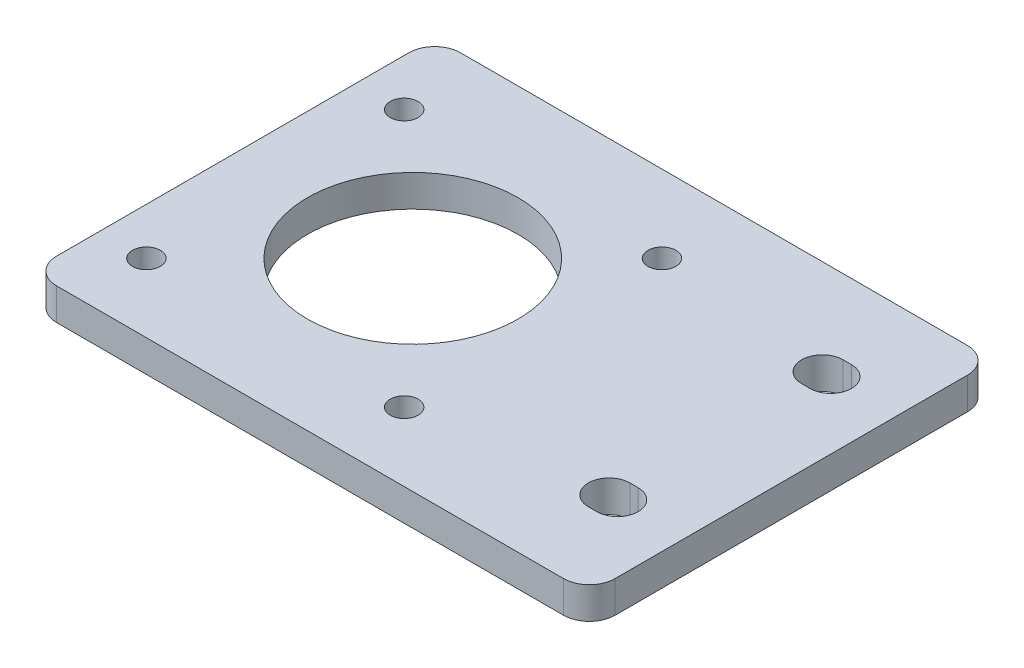
from build123d import *

# Parameters (mm, degrees)
SKETCH1_W           = 65
SKETCH1_H           = 47
SKETCH1_R           = 12.25
SKETCH1_R_2         = 1.623849847
BOSS_EXTRUDE1_DEPTH = 3.7
FILLET1_R           = 3


with BuildPart() as part:
    # Sketch1 → Boss-Extrude1 (new body)
    with BuildSketch(Plane(origin=(0, 0, 0), x_dir=(1, 0, 0), z_dir=(0, 1, 0))):
        with Locations((15.646990036, 10.777629745)):
            Rectangle(SKETCH1_W, SKETCH1_H)
        with Locations((4.096990036, 10.777629745)):
            Circle(SKETCH1_R, mode=Mode.SUBTRACT)
        with Locations((-11.403009964, -4.722370255)):
            Circle(SKETCH1_R_2, mode=Mode.SUBTRACT)
        with Locations((18.596990036, -4.722370255)):
            Circle(SKETCH1_R_2, mode=Mode.SUBTRACT)
        with Locations((18.596990036, 25.277629745)):
            Circle(SKETCH1_R_2, mode=Mode.SUBTRACT)
        with Locations((-11.403009964, 25.277629745)):
            Circle(SKETCH1_R_2, mode=Mode.SUBTRACT)
        with BuildLine():
            Line((39.356990036, 0.777629745), (40.336990036, 0.777629745))
            ThreePointArc((40.336990036, 0.777629745), (42.746990036, -1.632370255), (40.336990036, -4.042370255))
            Line((40.336990036, -4.042370255), (39.356990036, -4.042370255))
            ThreePointArc((39.356990036, -4.042370255), (36.946990036, -1.632370255), (39.356990036, 0.777629745))
        make_face(mode=Mode.SUBTRACT)
        with BuildLine():
            Line((39.356990036, 20.777629745), (40.336990036, 20.777629745))
            ThreePointArc((40.336990036, 20.777629745), (42.746990036, 23.187629745), (40.336990036, 25.597629745))
            Line((40.336990036, 25.597629745), (39.356990036, 25.597629745))
            ThreePointArc((39.356990036, 25.597629745), (36.946990036, 23.187629745), (39.356990036, 20.777629745))
        make_face(mode=Mode.SUBTRACT)
    extrude(amount=BOSS_EXTRUDE1_DEPTH)

    # Fillet1
    fillet1_edges = [part.edges().sort_by_distance(p)[0] for p in [
        (-16.853009964, 1.85, -34.277629745),
        (48.146990036, 1.85, -34.277629745),
        (48.146990036, 1.85, 12.722370255),
        (-16.853009964, 1.85, 12.722370255),
    ]]
    fillet(fillet1_edges, radius=FILLET1_R)


solid = part.part
